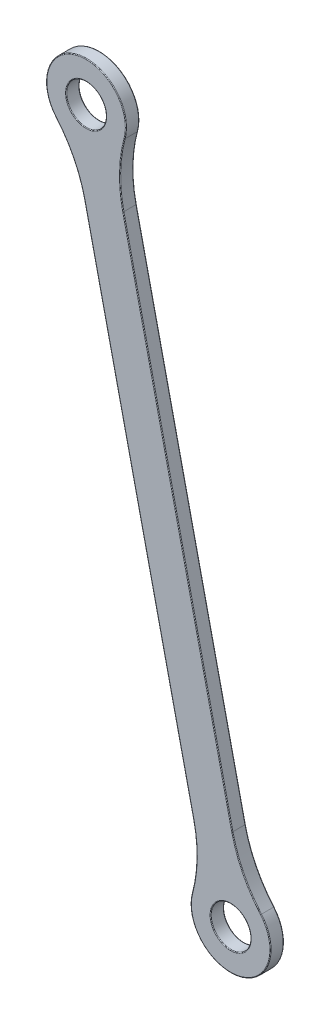
from build123d import *

# Parameters (mm, degrees)
DODANIE_WYCI_GNI_CIE1_DEPTH = 3
ZAOKR_GLENIE1_R             = 30
ZAOKR_GLENIE2_R             = 30
ZAOKR_GLENIE3_R             = 30
ZAOKR_GLENIE4_R             = 30
ZAOKR_GLENIE5_R             = 0.15


with BuildPart() as part:
    # Szkic2 → Dodanie-wyciągnięcie1 (new body)
    with BuildSketch(Plane.XY):
        with BuildLine():
            ThreePointArc((18.889354473, 82.491749621), (13.508250379, 85.889354473), (10.110645527, 80.508250379))
            Line((10.110645527, 80.508250379), (-22.506897562, 224.869241934))
            ThreePointArc((-22.506897562, 224.869241934), (-17.125793468, 221.471637082), (-13.728188616, 226.852741176))
            Line((-13.728188616, 226.852741176), (18.889354473, 82.491749621))
        make_face()
        with BuildLine():
            ThreePointArc((18.889354473, 82.491749621), (15.491749621, 77.110645527), (10.110645527, 80.508250379))
            Line((10.110645527, 80.508250379), (8.392884795, 88.110835339))
            ThreePointArc((8.392884795, 88.110835339), (16.483499242, 72.721291054), (17.171593741, 90.094334581))
            Line((17.171593741, 90.094334581), (18.889354473, 82.491749621))
        make_face()
        with BuildLine():
            ThreePointArc((-12.010427884, 219.250156217), (-20.101042331, 234.639700501), (-20.78913683, 217.266656975))
            Line((-20.78913683, 217.266656975), (-22.506897562, 224.869241934))
            ThreePointArc((-22.506897562, 224.869241934), (-19.10929271, 230.250346028), (-13.728188616, 226.852741176))
            Line((-13.728188616, 226.852741176), (-12.010427884, 219.250156217))
        make_face()
    extrude(amount=-DODANIE_WYCI_GNI_CIE1_DEPTH)

    # Zaokrąglenie1
    zaokr_glenie1_edges = [part.edges().sort_by_distance(p)[0] for p in [
        (-20.78913683, 217.266656975, -1.5),
    ]]
    fillet(zaokr_glenie1_edges, radius=ZAOKR_GLENIE1_R)

    # Zaokrąglenie2
    zaokr_glenie2_edges = [part.edges().sort_by_distance(p)[0] for p in [
        (-12.010427884, 219.250156217, -1.5),
    ]]
    fillet(zaokr_glenie2_edges, radius=ZAOKR_GLENIE2_R)

    # Zaokrąglenie3
    zaokr_glenie3_edges = [part.edges().sort_by_distance(p)[0] for p in [
        (8.392884795, 88.110835339, -1.5),
    ]]
    fillet(zaokr_glenie3_edges, radius=ZAOKR_GLENIE3_R)

    # Zaokrąglenie4
    zaokr_glenie4_edges = [part.edges().sort_by_distance(p)[0] for p in [
        (17.171593741, 90.094334581, -1.5),
    ]]
    fillet(zaokr_glenie4_edges, radius=ZAOKR_GLENIE4_R)

    # Zaokrąglenie5
    zaokr_glenie5_edges = [part.edges().sort_by_distance(p)[0] for p in [
        (-17.125793468, 221.471637082, -3),
        (-20.943505179, 213.964915113, 0),
        (-20.943505179, 213.964915113, -3),
        (15.491749621, 77.110645527, -3),
        (-20.101042331, 234.639700501, -3),
        (-20.101042331, 234.639700501, 0),
        (-10.451504967, 216.335522749, 0),
        (-10.451504967, 216.335522749, -3),
        (-6.198126017, 152.688746157, 0),
        (-6.198126017, 152.688746157, -3),
        (6.833961878, 91.025468806, 0),
        (6.833961878, 91.025468806, -3),
        (16.483499242, 72.721291054, 0),
        (16.483499242, 72.721291054, -3),
        (2.580582929, 154.672245399, -3),
        (2.580582929, 154.672245399, 0),
        (17.32596209, 93.396076442, 0),
        (17.32596209, 93.396076442, -3),
        (15.491749621, 77.110645527, 0),
        (-17.125793468, 221.471637082, 0),
    ]]
    fillet(zaokr_glenie5_edges, radius=ZAOKR_GLENIE5_R)


solid = part.part
